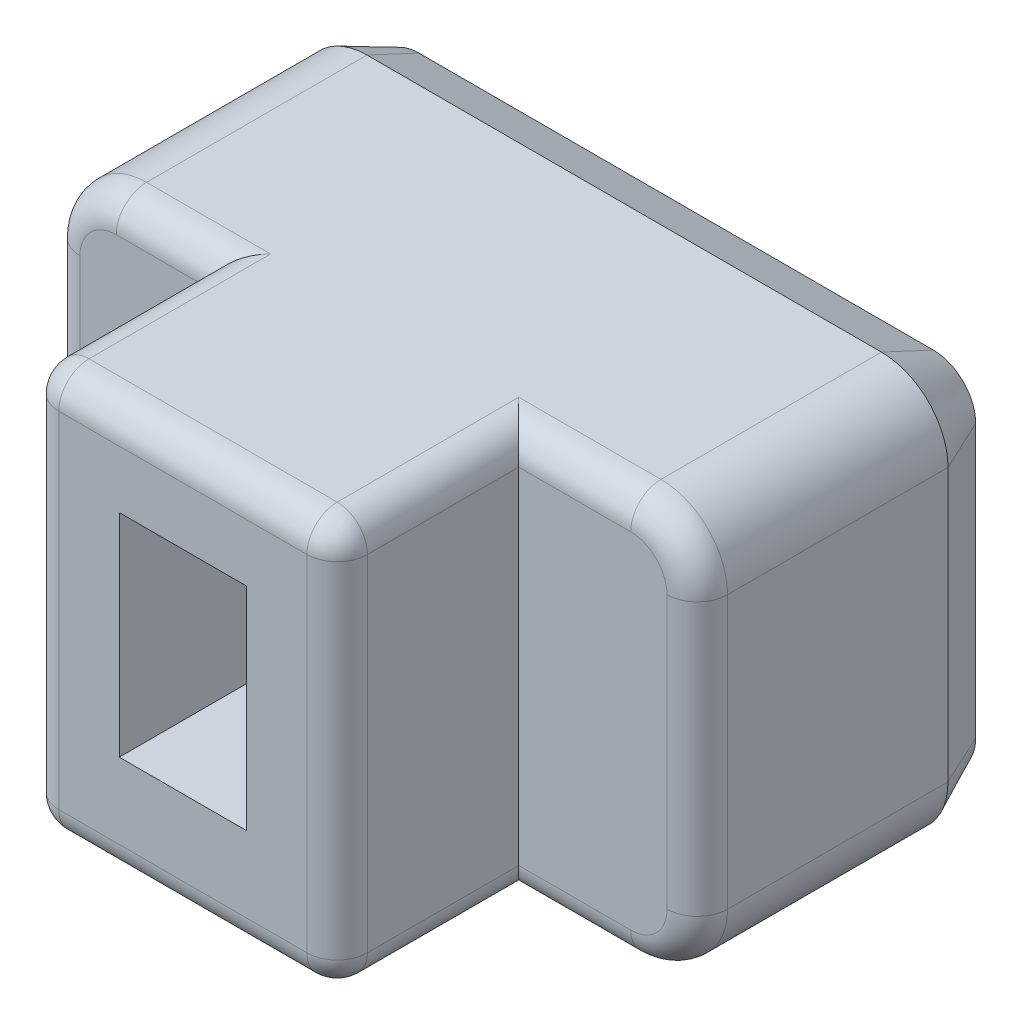
from build123d import *

# Parameters (mm, degrees)
BOSS_EXTRU_1_DEPTH      = 8
ESQUISSE3_W             = 2.1
ESQUISSE3_H             = 3.5
ENL_V_MAT_EXTRU_1_DEPTH = 3
ESQUISSE4_OUTSIDE_W     = 15.69
ESQUISSE4_OUTSIDE_H     = 11.69
ESQUISSE4_OUTSIDE_W_2   = 5.1
ESQUISSE4_OUTSIDE_H_2   = 6.7
ENL_V_MAT_EXTRU_2_DEPTH = 3
CONG_1_R                = 0.5
CHANFREIN1_SIZE         = 0.4
CHANFREIN1_SIZE2        = 0.857802768
ENL_V_MAT_EXTRU_3_DEPTH = 0.2
BOSS_EXTRU_2_DEPTH      = 0.2
BOSS_EXTRU_2_2_DEPTH    = 0.2
BOSS_EXTRU_2_3_DEPTH    = 0.2


with BuildPart() as part:
    # Esquisse2 → Boss.-Extru.1 (new body)
    with BuildSketch(Plane.XY):
        with BuildLine():
            Line((1.1, 0), (9.6, 0))
            ThreePointArc((9.6, 0), (10.377817459, 0.322182541), (10.7, 1.1))
            Line((10.7, 1.1), (10.7, 5.6))
            ThreePointArc((10.7, 5.6), (10.377817459, 6.377817459), (9.6, 6.7))
            Line((9.6, 6.7), (1.1, 6.7))
            ThreePointArc((1.1, 6.7), (0.322182541, 6.377817459), (0, 5.6))
            Line((0, 5.6), (0, 1.1))
            ThreePointArc((0, 1.1), (0.322182541, 0.322182541), (1.1, 0))
        make_face()
    extrude(amount=BOSS_EXTRU_1_DEPTH)

    # Esquisse3 → Enlèv. mat.-Extru.1 (cut)
    with BuildSketch(Plane.XY.offset(8)):
        with Locations((5.2, 3.5)):
            Rectangle(ESQUISSE3_W, ESQUISSE3_H)
    extrude(amount=-ENL_V_MAT_EXTRU_1_DEPTH, mode=Mode.SUBTRACT)

    # Esquisse4 outside → Enlèv. mat.-Extru.2 (cut)
    with BuildSketch(Plane.XY.offset(8)):
        with Locations((5.35, 3.35)):
            Rectangle(ESQUISSE4_OUTSIDE_W, ESQUISSE4_OUTSIDE_H)
        with Locations((5.2, 3.35)):
            Rectangle(ESQUISSE4_OUTSIDE_W_2, ESQUISSE4_OUTSIDE_H_2, mode=Mode.SUBTRACT)
    extrude(amount=-ENL_V_MAT_EXTRU_2_DEPTH, mode=Mode.SUBTRACT)

    # Congé1
    cong_1_edges = [part.edges().sort_by_distance(p)[0] for p in [
        (8.675, 0, 5),
        (10.377817459, 0.322182541, 5),
        (10.7, 3.35, 5),
        (10.377817459, 6.377817459, 5),
        (1.875, 6.7, 5),
        (0.322182541, 6.377817459, 5),
        (1.875, 0, 5),
        (0.322182541, 0.322182541, 5),
        (7.75, 6.7, 6.5),
        (2.65, 6.7, 6.5),
        (7.75, 0, 6.5),
        (2.65, 0, 6.5),
        (2.65, 3.35, 8),
        (5.2, 6.7, 8),
        (7.75, 3.35, 8),
        (5.2, 0, 8),
        (8.675, 6.7, 5),
        (0, 3.35, 5),
    ]]
    fillet(cong_1_edges, radius=CONG_1_R)

    # Chanfrein1
    chanfrein1_edges = [part.edges().sort_by_distance(p)[0] for p in [
        (5.35, 0, 0),
        (10.377817459, 0.322182541, 0),
        (0.322182541, 0.322182541, 0),
        (10.7, 3.35, 0),
        (0, 3.35, 0),
        (10.377817459, 6.377817459, 0),
        (0.322182541, 6.377817459, 0),
        (5.35, 6.7, 0),
    ]]
    chanfrein1_side = [part.faces().sort_by_distance(p)[0] for p in [
        (5.35, 3.35, 0),
    ]]
    chamfer(chanfrein1_edges, length=CHANFREIN1_SIZE, length2=CHANFREIN1_SIZE2, reference=chanfrein1_side[0])

    # Esquisse5 → Enlèv. mat.-Extru.3 (cut)
    # profile 1 of 3: a face of its own
    with BuildSketch(Plane.XY):
        with BuildLine():
            add(Edge.make_bspline(
                [(3.473958259, 1.906882869), (3.431539054, 1.908181766), (3.347907306, 1.910742613), (3.22443768, 1.927864642), (3.105710696, 1.957677609), (2.99128617, 1.997854543), (2.882166116, 2.049560358), (2.780900865, 2.114498856), (2.685700868, 2.189121997), (2.599897942, 2.276757259), (2.520967095, 2.37481173), (2.451459557, 2.484423401), (2.390718691, 2.604945686), (2.338761785, 2.736324473), (2.296667928, 2.879087989), (2.267869258, 3.033597694), (2.249768827, 3.198930565), (2.247493899, 3.312981988), (2.246323183, 3.37167472)],
                knots=[0, 0, 0, 0, 0.945803491, 1.864702528, 2.772795634, 3.670969147, 4.56499557, 5.458297987, 6.348008831, 7.256321141, 8.186507106, 9.150053397, 10.144425887, 11.191618815, 12.296204967, 13.457548109, 14.691612581, 16, 16, 16, 16], degree=3))
            add(Edge.make_bspline(
                [(2.246323183, 3.37167472), (2.247317892, 3.429838218), (2.249245174, 3.542532017), (2.265353623, 3.705604622), (2.293107691, 3.856767307), (2.331759392, 3.996079622), (2.380540268, 4.123797674), (2.438951669, 4.240129647), (2.50603934, 4.345446222), (2.583698587, 4.438327145), (2.669401524, 4.520347703), (2.763664324, 4.591397547), (2.866770327, 4.650684947), (2.978129172, 4.697700252), (3.096414393, 4.73388993), (3.221099617, 4.760431969), (3.352405221, 4.775920976), (3.44214151, 4.778036153), (3.487908657, 4.779114933)],
                knots=[0, 0, 0, 0, 1.305707338, 2.52985338, 3.674329165, 4.75233399, 5.771362634, 6.738924273, 7.670488062, 8.568360796, 9.450412659, 10.328584496, 11.212065556, 12.113826821, 13.036663953, 13.98544029, 14.972537736, 16, 16, 16, 16], degree=3))
            add(Edge.make_bspline(
                [(3.487908657, 4.779114933), (3.514275007, 4.778651363), (3.568643326, 4.777695466), (3.651614523, 4.770146072), (3.737551149, 4.759701088), (3.82406524, 4.744003691), (3.909849625, 4.725477043), (3.992259546, 4.704711308), (4.069878388, 4.683337522), (4.118125349, 4.664781272), (4.141252324, 4.655886412)],
                knots=[0, 0, 0, 0, 0.947130429, 1.953015509, 2.991432969, 4.05655227, 5.110614388, 6.143875491, 7.110274616, 8, 8, 8, 8], degree=3))
            Line((4.141252324, 4.655886412), (4.141252324, 5.032547174))
            add(Edge.make_bspline(
                [(4.141252324, 5.032547174), (4.117621198, 5.042470777), (4.069195572, 5.062806528), (3.991762064, 5.087109849), (3.90931105, 5.108881816), (3.791439485, 5.132298487), (3.638259187, 5.154210511), (3.513574194, 5.156796764), (3.450707594, 5.158100761)],
                knots=[0, 0, 0, 0, 0.652749763, 1.337634765, 2.065699827, 2.824796115, 4.399051334, 6, 6, 6, 6], degree=3))
            add(Edge.make_bspline(
                [(3.450707594, 5.158100761), (3.387865351, 5.156603594), (3.265122554, 5.153679343), (3.086748237, 5.131226276), (2.91920182, 5.093292958), (2.763128847, 5.039772722), (2.618382665, 4.972260512), (2.485306328, 4.891488208), (2.365516357, 4.795975395), (2.256885923, 4.688349403), (2.160339501, 4.567876338), (2.077431975, 4.43393724), (2.005398117, 4.288392368), (1.94802079, 4.129568633), (1.902220187, 3.959774557), (1.8702011, 3.778490298), (1.849340475, 3.586587121), (1.84740288, 3.454659186), (1.846411757, 3.387175163)],
                knots=[0, 0, 0, 0, 1.110820354, 2.169642453, 3.172363495, 4.143000197, 5.080877828, 5.991111456, 6.888465404, 7.783083599, 8.689700368, 9.611027733, 10.562902993, 11.555629611, 12.591556361, 13.668419844, 14.807345784, 16, 16, 16, 16], degree=3))
            add(Edge.make_bspline(
                [(1.846411757, 3.387175163), (1.847665631, 3.320460305), (1.850126336, 3.189533615), (1.872023058, 2.99738647), (1.905128011, 2.813067665), (1.954471316, 2.638072663), (2.015151247, 2.472606208), (2.0889561, 2.31878217), (2.174395924, 2.176256164), (2.273094138, 2.047012489), (2.382556308, 1.929632833), (2.504489504, 1.827040733), (2.636796375, 1.737367141), (2.779854991, 1.661886668), (2.933245914, 1.602110794), (3.095840506, 1.558589283), (3.26799325, 1.532519835), (3.385772467, 1.529462123), (3.446057461, 1.527897041)],
                knots=[0, 0, 0, 0, 1.160705765, 2.277863851, 3.361653773, 4.41651977, 5.437941951, 6.425340498, 7.38148348, 8.32479146, 9.250392758, 10.16918771, 11.091989253, 12.027194015, 12.978185521, 13.951022668, 14.951236128, 16, 16, 16, 16], degree=3))
            add(Edge.make_bspline(
                [(3.446057461, 1.527897041), (3.478354278, 1.528445703), (3.542746901, 1.529539612), (3.6383019, 1.535173143), (3.731221923, 1.547596874), (3.82037205, 1.561459371), (3.904096508, 1.580341741), (3.981148167, 1.601415147), (4.049664682, 1.625910127), (4.091493725, 1.644683912), (4.111026461, 1.653450628)],
                knots=[0, 0, 0, 0, 1.137094954, 2.267112863, 3.366902482, 4.435879965, 5.442006, 6.386396518, 7.246502268, 8, 8, 8, 8], degree=3))
            Line((4.111026461, 1.653450628), (4.111026461, 2.03011139))
            add(Edge.make_bspline(
                [(4.111026461, 2.03011139), (4.06266427, 2.013419514), (3.962633799, 1.978894688), (3.805626321, 1.939342059), (3.641285247, 1.911561709), (3.529613029, 1.908439102), (3.473958259, 1.906882869)],
                knots=[0, 0, 0, 0, 0.941076967, 1.946486941, 2.97657806, 4, 4, 4, 4], degree=3))
        make_face()
    # profile 2 of 3: a face of its own
    with BuildSketch(Plane.XY):
        Polygon((4.89116375, 1.592998901), (4.89116375, 4.708587918), (6.409432129, 4.708587918), (6.409432129, 5.092998901), (4.512177922, 5.092998901), (4.512177922, 1.592998901), align=None)
    # profile 3 of 3: a face of its own
    with BuildSketch(Plane.XY):
        with BuildLine():
            Line((7.093466673, 3.643707493), (7.093466673, 5.092998901))
            Line((7.093466673, 5.092998901), (6.714480845, 5.092998901))
            Line((6.714480845, 5.092998901), (6.714480845, 1.592998901))
            Line((6.714480845, 1.592998901), (7.521278896, 1.592998901))
            add(Edge.make_bspline(
                [(7.521278896, 1.592998901), (7.554096924, 1.592942505), (7.617175541, 1.592834109), (7.708064506, 1.597711589), (7.791414819, 1.601192751), (7.890012269, 1.612024466), (8.003216696, 1.628359769), (8.089039572, 1.652081134), (8.130446301, 1.663525916)],
                knots=[0, 0, 0, 0, 0.959554404, 1.844332764, 2.661564738, 3.398314227, 4.744771778, 6, 6, 6, 6], degree=3))
            add(Edge.make_bspline(
                [(8.130446301, 1.663525916), (8.156949908, 1.672154281), (8.209109417, 1.689135037), (8.283277162, 1.721205475), (8.352969194, 1.75675016), (8.417332441, 1.797577677), (8.478081778, 1.841298056), (8.533457744, 1.89032058), (8.582906518, 1.944498616), (8.629231993, 2.001565927), (8.669117943, 2.06371452), (8.704344824, 2.129167246), (8.734097495, 2.198634792), (8.757330817, 2.272041851), (8.777703953, 2.348645856), (8.789896516, 2.429473796), (8.799244739, 2.513765539), (8.799789027, 2.571306576), (8.800065433, 2.600527688)],
                knots=[0, 0, 0, 0, 1.07357345, 2.112809139, 3.110193467, 4.085267968, 5.047037933, 5.992018707, 6.928941706, 7.871139026, 8.821036432, 9.769733187, 10.733150549, 11.727997694, 12.734876425, 13.783983603, 14.874638588, 16, 16, 16, 16], degree=3))
            add(Edge.make_bspline(
                [(8.800065433, 2.600527688), (8.799374134, 2.634924014), (8.798023762, 2.702113265), (8.785991719, 2.799802483), (8.767628733, 2.892214709), (8.741422795, 2.978934182), (8.707575023, 3.060127032), (8.668530996, 3.135817254), (8.622914599, 3.205993695), (8.570903145, 3.270076411), (8.513357149, 3.329279369), (8.450562943, 3.382719131), (8.382434736, 3.430682634), (8.308500909, 3.471915432), (8.230432938, 3.509703838), (8.147026227, 3.539969727), (8.060283428, 3.566965779), (8.000360686, 3.579837706), (7.970016717, 3.586355854)],
                knots=[0, 0, 0, 0, 1.167138933, 2.279871147, 3.335833019, 4.362251633, 5.349137281, 6.317935046, 7.249504024, 8.184903669, 9.115109586, 10.048204477, 10.979979806, 11.938242509, 12.918874561, 13.92060957, 14.947028185, 16, 16, 16, 16], degree=3))
            Line((7.970016717, 3.586355854), (7.970016717, 3.596431142))
            Line((7.970016717, 3.596431142), (8.986070748, 5.092998901))
            Line((8.986070748, 5.092998901), (8.509432129, 5.092998901))
            Line((8.509432129, 5.092998901), (7.55150476, 3.643707493))
            Line((7.55150476, 3.643707493), (7.093466673, 3.643707493))
        make_face()
        with BuildLine():
            Line((7.093466673, 1.977409884), (7.093466673, 3.259296509))
            Line((7.093466673, 3.259296509), (7.467802368, 3.259296509))
            add(Edge.make_bspline(
                [(7.467802368, 3.259296509), (7.495703188, 3.259128627), (7.549448614, 3.258805235), (7.627010518, 3.256885326), (7.698280278, 3.251724682), (7.783113473, 3.245366527), (7.879585511, 3.230950138), (7.951869043, 3.20920184), (7.986292182, 3.198844782)],
                knots=[0, 0, 0, 0, 0.957988922, 1.845376735, 2.663139964, 3.410793096, 4.766958009, 6, 6, 6, 6], degree=3))
            add(Edge.make_bspline(
                [(7.986292182, 3.198844782), (8.017697494, 3.186819148), (8.078891603, 3.163386871), (8.162109017, 3.113996077), (8.233529542, 3.053667604), (8.293236185, 2.983089079), (8.340977939, 2.90156631), (8.373652324, 2.808166734), (8.394184317, 2.703718157), (8.396578199, 2.630340412), (8.397828941, 2.592002444)],
                knots=[0, 0, 0, 0, 1.01977405, 1.987057631, 2.922156739, 3.846200948, 4.781267153, 5.773826012, 6.836881834, 8, 8, 8, 8], degree=3))
            add(Edge.make_bspline(
                [(8.397828941, 2.592002444), (8.396616987, 2.556227882), (8.394294709, 2.487678663), (8.373321998, 2.39105101), (8.342899197, 2.304291529), (8.2980566, 2.229205956), (8.241992236, 2.164922532), (8.176829218, 2.110222858), (8.102444295, 2.064068958), (8.047169703, 2.043154497), (8.018843112, 2.032436456)],
                knots=[0, 0, 0, 0, 1.179354755, 2.259813816, 3.249972487, 4.202088527, 5.127084211, 6.053022886, 7.002231929, 8, 8, 8, 8], degree=3))
            add(Edge.make_bspline(
                [(8.018843112, 2.032436456), (7.988257802, 2.023506093), (7.922742948, 2.004376927), (7.834473257, 1.991338922), (7.754349226, 1.984882822), (7.684364832, 1.979767195), (7.606541346, 1.977905116), (7.552021299, 1.977579568), (7.523603963, 1.977409884)],
                knots=[0, 0, 0, 0, 1.145392119, 2.453471849, 3.199908543, 4.03831046, 4.977513876, 6, 6, 6, 6], degree=3))
            Line((7.523603963, 1.977409884), (7.093466673, 1.977409884))
        make_face(mode=Mode.SUBTRACT)
    extrude(amount=ENL_V_MAT_EXTRU_3_DEPTH, mode=Mode.SUBTRACT)


with BuildPart() as body_2:
    # Esquisse5_4 → Boss.-Extru.2 (new body)
    with BuildSketch(Plane.XY):
        with BuildLine():
            add(Edge.make_bspline(
                [(3.473958259, 1.906882869), (3.431539054, 1.908181766), (3.347907306, 1.910742613), (3.22443768, 1.927864642), (3.105710696, 1.957677609), (2.99128617, 1.997854543), (2.882166116, 2.049560358), (2.780900865, 2.114498856), (2.685700868, 2.189121997), (2.599897942, 2.276757259), (2.520967095, 2.37481173), (2.451459557, 2.484423401), (2.390718691, 2.604945686), (2.338761785, 2.736324473), (2.296667928, 2.879087989), (2.267869258, 3.033597694), (2.249768827, 3.198930565), (2.247493899, 3.312981988), (2.246323183, 3.37167472)],
                knots=[0, 0, 0, 0, 0.945803491, 1.864702528, 2.772795634, 3.670969147, 4.56499557, 5.458297987, 6.348008831, 7.256321141, 8.186507106, 9.150053397, 10.144425887, 11.191618815, 12.296204967, 13.457548109, 14.691612581, 16, 16, 16, 16], degree=3))
            add(Edge.make_bspline(
                [(2.246323183, 3.37167472), (2.247317892, 3.429838218), (2.249245174, 3.542532017), (2.265353623, 3.705604622), (2.293107691, 3.856767307), (2.331759392, 3.996079622), (2.380540268, 4.123797674), (2.438951669, 4.240129647), (2.50603934, 4.345446222), (2.583698587, 4.438327145), (2.669401524, 4.520347703), (2.763664324, 4.591397547), (2.866770327, 4.650684947), (2.978129172, 4.697700252), (3.096414393, 4.73388993), (3.221099617, 4.760431969), (3.352405221, 4.775920976), (3.44214151, 4.778036153), (3.487908657, 4.779114933)],
                knots=[0, 0, 0, 0, 1.305707338, 2.52985338, 3.674329165, 4.75233399, 5.771362634, 6.738924273, 7.670488062, 8.568360796, 9.450412659, 10.328584496, 11.212065556, 12.113826821, 13.036663953, 13.98544029, 14.972537736, 16, 16, 16, 16], degree=3))
            add(Edge.make_bspline(
                [(3.487908657, 4.779114933), (3.514275007, 4.778651363), (3.568643326, 4.777695466), (3.651614523, 4.770146072), (3.737551149, 4.759701088), (3.82406524, 4.744003691), (3.909849625, 4.725477043), (3.992259546, 4.704711308), (4.069878388, 4.683337522), (4.118125349, 4.664781272), (4.141252324, 4.655886412)],
                knots=[0, 0, 0, 0, 0.947130429, 1.953015509, 2.991432969, 4.05655227, 5.110614388, 6.143875491, 7.110274616, 8, 8, 8, 8], degree=3))
            Line((4.141252324, 4.655886412), (4.141252324, 5.032547174))
            add(Edge.make_bspline(
                [(4.141252324, 5.032547174), (4.117621198, 5.042470777), (4.069195572, 5.062806528), (3.991762064, 5.087109849), (3.90931105, 5.108881816), (3.791439485, 5.132298487), (3.638259187, 5.154210511), (3.513574194, 5.156796764), (3.450707594, 5.158100761)],
                knots=[0, 0, 0, 0, 0.652749763, 1.337634765, 2.065699827, 2.824796115, 4.399051334, 6, 6, 6, 6], degree=3))
            add(Edge.make_bspline(
                [(3.450707594, 5.158100761), (3.387865351, 5.156603594), (3.265122554, 5.153679343), (3.086748237, 5.131226276), (2.91920182, 5.093292958), (2.763128847, 5.039772722), (2.618382665, 4.972260512), (2.485306328, 4.891488208), (2.365516357, 4.795975395), (2.256885923, 4.688349403), (2.160339501, 4.567876338), (2.077431975, 4.43393724), (2.005398117, 4.288392368), (1.94802079, 4.129568633), (1.902220187, 3.959774557), (1.8702011, 3.778490298), (1.849340475, 3.586587121), (1.84740288, 3.454659186), (1.846411757, 3.387175163)],
                knots=[0, 0, 0, 0, 1.110820354, 2.169642453, 3.172363495, 4.143000197, 5.080877828, 5.991111456, 6.888465404, 7.783083599, 8.689700368, 9.611027733, 10.562902993, 11.555629611, 12.591556361, 13.668419844, 14.807345784, 16, 16, 16, 16], degree=3))
            add(Edge.make_bspline(
                [(1.846411757, 3.387175163), (1.847665631, 3.320460305), (1.850126336, 3.189533615), (1.872023058, 2.99738647), (1.905128011, 2.813067665), (1.954471316, 2.638072663), (2.015151247, 2.472606208), (2.0889561, 2.31878217), (2.174395924, 2.176256164), (2.273094138, 2.047012489), (2.382556308, 1.929632833), (2.504489504, 1.827040733), (2.636796375, 1.737367141), (2.779854991, 1.661886668), (2.933245914, 1.602110794), (3.095840506, 1.558589283), (3.26799325, 1.532519835), (3.385772467, 1.529462123), (3.446057461, 1.527897041)],
                knots=[0, 0, 0, 0, 1.160705765, 2.277863851, 3.361653773, 4.41651977, 5.437941951, 6.425340498, 7.38148348, 8.32479146, 9.250392758, 10.16918771, 11.091989253, 12.027194015, 12.978185521, 13.951022668, 14.951236128, 16, 16, 16, 16], degree=3))
            add(Edge.make_bspline(
                [(3.446057461, 1.527897041), (3.478354278, 1.528445703), (3.542746901, 1.529539612), (3.6383019, 1.535173143), (3.731221923, 1.547596874), (3.82037205, 1.561459371), (3.904096508, 1.580341741), (3.981148167, 1.601415147), (4.049664682, 1.625910127), (4.091493725, 1.644683912), (4.111026461, 1.653450628)],
                knots=[0, 0, 0, 0, 1.137094954, 2.267112863, 3.366902482, 4.435879965, 5.442006, 6.386396518, 7.246502268, 8, 8, 8, 8], degree=3))
            Line((4.111026461, 1.653450628), (4.111026461, 2.03011139))
            add(Edge.make_bspline(
                [(4.111026461, 2.03011139), (4.06266427, 2.013419514), (3.962633799, 1.978894688), (3.805626321, 1.939342059), (3.641285247, 1.911561709), (3.529613029, 1.908439102), (3.473958259, 1.906882869)],
                knots=[0, 0, 0, 0, 0.941076967, 1.946486941, 2.97657806, 4, 4, 4, 4], degree=3))
        make_face()
    extrude(amount=-BOSS_EXTRU_2_DEPTH)


with BuildPart() as body_3:
    # Esquisse5_4 → Boss.-Extru.2 2 (new body)
    with BuildSketch(Plane.XY):
        Polygon((4.89116375, 1.592998901), (4.89116375, 4.708587918), (6.409432129, 4.708587918), (6.409432129, 5.092998901), (4.512177922, 5.092998901), (4.512177922, 1.592998901), align=None)
    extrude(amount=-BOSS_EXTRU_2_2_DEPTH)


with BuildPart() as body_4:
    # Esquisse5_4 → Boss.-Extru.2 3 (new body)
    with BuildSketch(Plane.XY):
        with BuildLine():
            Line((7.093466673, 3.643707493), (7.093466673, 5.092998901))
            Line((7.093466673, 5.092998901), (6.714480845, 5.092998901))
            Line((6.714480845, 5.092998901), (6.714480845, 1.592998901))
            Line((6.714480845, 1.592998901), (7.521278896, 1.592998901))
            add(Edge.make_bspline(
                [(7.521278896, 1.592998901), (7.554096924, 1.592942505), (7.617175541, 1.592834109), (7.708064506, 1.597711589), (7.791414819, 1.601192751), (7.890012269, 1.612024466), (8.003216696, 1.628359769), (8.089039572, 1.652081134), (8.130446301, 1.663525916)],
                knots=[0, 0, 0, 0, 0.959554404, 1.844332764, 2.661564738, 3.398314227, 4.744771778, 6, 6, 6, 6], degree=3))
            add(Edge.make_bspline(
                [(8.130446301, 1.663525916), (8.156949908, 1.672154281), (8.209109417, 1.689135037), (8.283277162, 1.721205475), (8.352969194, 1.75675016), (8.417332441, 1.797577677), (8.478081778, 1.841298056), (8.533457744, 1.89032058), (8.582906518, 1.944498616), (8.629231993, 2.001565927), (8.669117943, 2.06371452), (8.704344824, 2.129167246), (8.734097495, 2.198634792), (8.757330817, 2.272041851), (8.777703953, 2.348645856), (8.789896516, 2.429473796), (8.799244739, 2.513765539), (8.799789027, 2.571306576), (8.800065433, 2.600527688)],
                knots=[0, 0, 0, 0, 1.07357345, 2.112809139, 3.110193467, 4.085267968, 5.047037933, 5.992018707, 6.928941706, 7.871139026, 8.821036432, 9.769733187, 10.733150549, 11.727997694, 12.734876425, 13.783983603, 14.874638588, 16, 16, 16, 16], degree=3))
            add(Edge.make_bspline(
                [(8.800065433, 2.600527688), (8.799374134, 2.634924014), (8.798023762, 2.702113265), (8.785991719, 2.799802483), (8.767628733, 2.892214709), (8.741422795, 2.978934182), (8.707575023, 3.060127032), (8.668530996, 3.135817254), (8.622914599, 3.205993695), (8.570903145, 3.270076411), (8.513357149, 3.329279369), (8.450562943, 3.382719131), (8.382434736, 3.430682634), (8.308500909, 3.471915432), (8.230432938, 3.509703838), (8.147026227, 3.539969727), (8.060283428, 3.566965779), (8.000360686, 3.579837706), (7.970016717, 3.586355854)],
                knots=[0, 0, 0, 0, 1.167138933, 2.279871147, 3.335833019, 4.362251633, 5.349137281, 6.317935046, 7.249504024, 8.184903669, 9.115109586, 10.048204477, 10.979979806, 11.938242509, 12.918874561, 13.92060957, 14.947028185, 16, 16, 16, 16], degree=3))
            Line((7.970016717, 3.586355854), (7.970016717, 3.596431142))
            Line((7.970016717, 3.596431142), (8.986070748, 5.092998901))
            Line((8.986070748, 5.092998901), (8.509432129, 5.092998901))
            Line((8.509432129, 5.092998901), (7.55150476, 3.643707493))
            Line((7.55150476, 3.643707493), (7.093466673, 3.643707493))
        make_face()
        with BuildLine():
            Line((7.093466673, 1.977409884), (7.093466673, 3.259296509))
            Line((7.093466673, 3.259296509), (7.467802368, 3.259296509))
            add(Edge.make_bspline(
                [(7.467802368, 3.259296509), (7.495703188, 3.259128627), (7.549448614, 3.258805235), (7.627010518, 3.256885326), (7.698280278, 3.251724682), (7.783113473, 3.245366527), (7.879585511, 3.230950138), (7.951869043, 3.20920184), (7.986292182, 3.198844782)],
                knots=[0, 0, 0, 0, 0.957988922, 1.845376735, 2.663139964, 3.410793096, 4.766958009, 6, 6, 6, 6], degree=3))
            add(Edge.make_bspline(
                [(7.986292182, 3.198844782), (8.017697494, 3.186819148), (8.078891603, 3.163386871), (8.162109017, 3.113996077), (8.233529542, 3.053667604), (8.293236185, 2.983089079), (8.340977939, 2.90156631), (8.373652324, 2.808166734), (8.394184317, 2.703718157), (8.396578199, 2.630340412), (8.397828941, 2.592002444)],
                knots=[0, 0, 0, 0, 1.01977405, 1.987057631, 2.922156739, 3.846200948, 4.781267153, 5.773826012, 6.836881834, 8, 8, 8, 8], degree=3))
            add(Edge.make_bspline(
                [(8.397828941, 2.592002444), (8.396616987, 2.556227882), (8.394294709, 2.487678663), (8.373321998, 2.39105101), (8.342899197, 2.304291529), (8.2980566, 2.229205956), (8.241992236, 2.164922532), (8.176829218, 2.110222858), (8.102444295, 2.064068958), (8.047169703, 2.043154497), (8.018843112, 2.032436456)],
                knots=[0, 0, 0, 0, 1.179354755, 2.259813816, 3.249972487, 4.202088527, 5.127084211, 6.053022886, 7.002231929, 8, 8, 8, 8], degree=3))
            add(Edge.make_bspline(
                [(8.018843112, 2.032436456), (7.988257802, 2.023506093), (7.922742948, 2.004376927), (7.834473257, 1.991338922), (7.754349226, 1.984882822), (7.684364832, 1.979767195), (7.606541346, 1.977905116), (7.552021299, 1.977579568), (7.523603963, 1.977409884)],
                knots=[0, 0, 0, 0, 1.145392119, 2.453471849, 3.199908543, 4.03831046, 4.977513876, 6, 6, 6, 6], degree=3))
            Line((7.523603963, 1.977409884), (7.093466673, 1.977409884))
        make_face(mode=Mode.SUBTRACT)
    extrude(amount=-BOSS_EXTRU_2_3_DEPTH)


solid = Compound([part.part, body_2.part, body_3.part, body_4.part])
